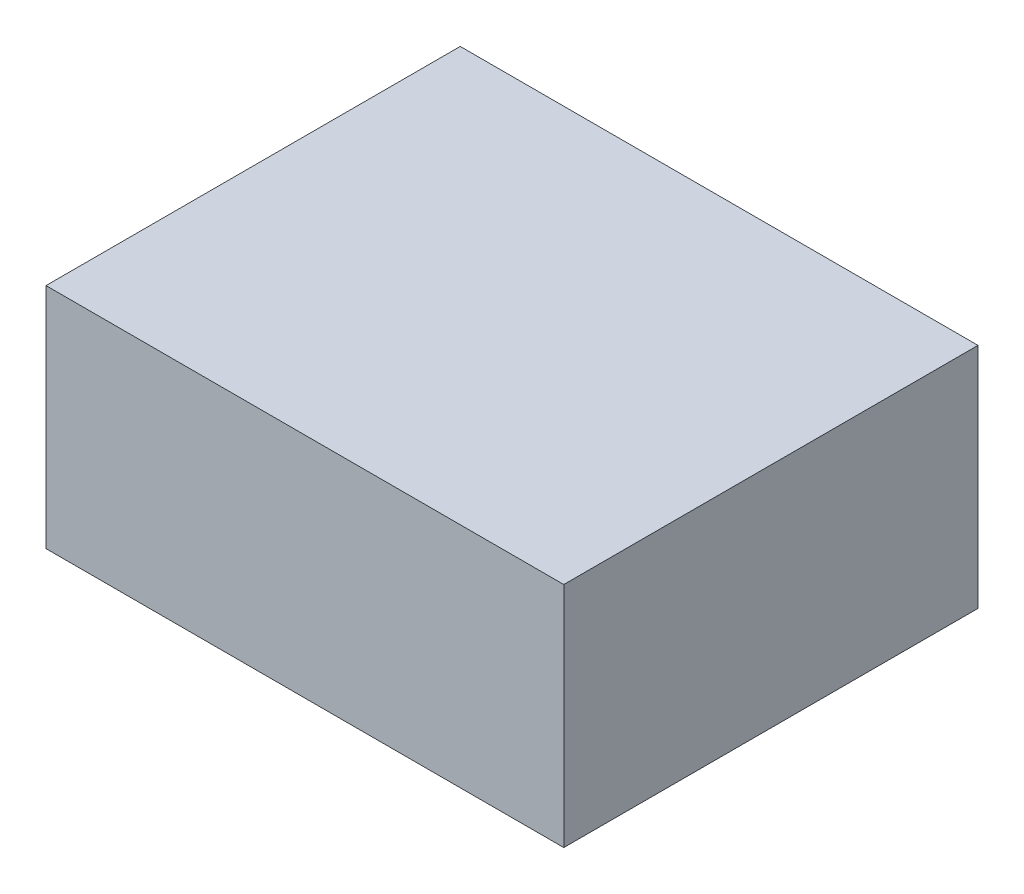
from build123d import *

# Parameters (mm, degrees)
SKETCH1_W           = 5
SKETCH1_H           = 4
BOSS_EXTRUDE1_DEPTH = 2.2


with BuildPart() as part:
    # Sketch1 → Boss-Extrude1 (new body)
    with BuildSketch(Plane(origin=(0, 0, 0), x_dir=(1, 0, 0), z_dir=(0, 1, 0))):
        Rectangle(SKETCH1_W, SKETCH1_H)
    extrude(amount=BOSS_EXTRUDE1_DEPTH)


solid = part.part
